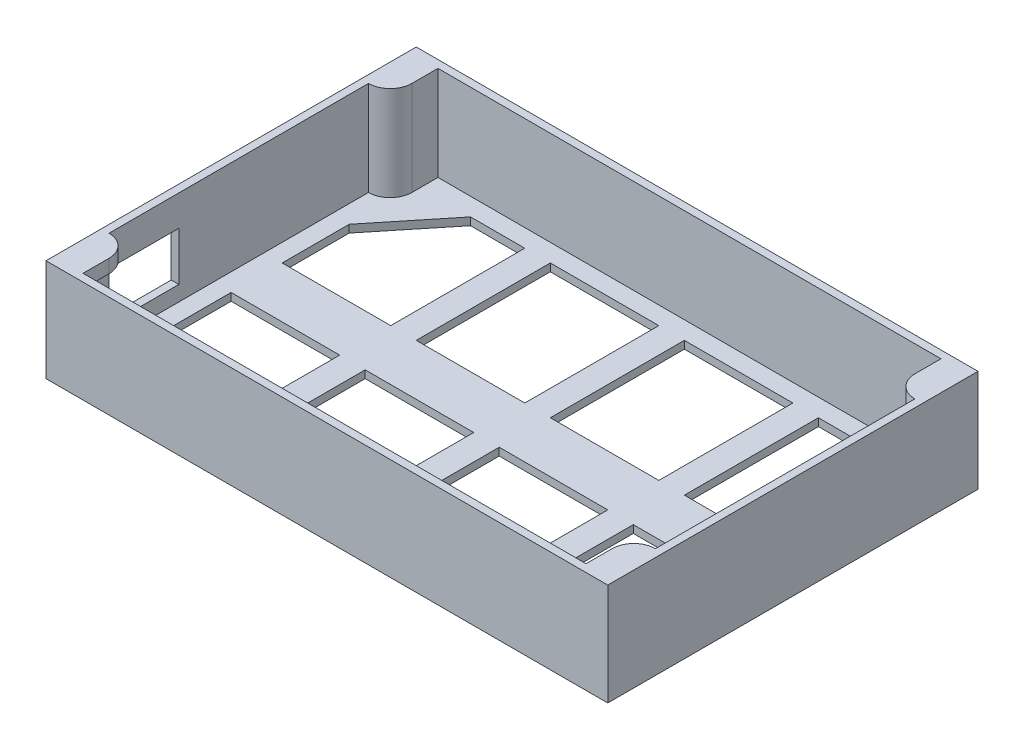
from build123d import *

# Parameters (mm, degrees)
SKETCH1_W           = 220
SKETCH1_H           = 145
SKETCH1_W_2         = 42.5
SKETCH1_H_2         = 52.5
BOSS_EXTRUDE1_DEPTH = 3
SKETCH2_W           = 220
SKETCH2_H           = 145
BOSS_EXTRUDE2_DEPTH = 37
SKETCH3_W           = 27.3375
SKETCH3_H           = 19.05
CUT_EXTRUDE1_DEPTH  = 3
SKETCH3_6_W         = 53.975
SKETCH3_6_H         = 31.75
CUT_EXTRUDE2_DEPTH  = 8.5


with BuildPart() as part:
    # Sketch1 → Boss-Extrude1 (new body)
    with BuildSketch(Plane(origin=(0, 0, 0), x_dir=(1, 0, 0), z_dir=(0, 1, 0))):
        with Locations((110, 72.5)):
            Rectangle(SKETCH1_W, SKETCH1_H)
        Polygon((10, 82.5), (52.5, 82.5), (52.5, 135), (31.25, 135), (10, 108.75), align=None, mode=Mode.SUBTRACT)
        with Locations((83.75, 108.75)):
            Rectangle(SKETCH1_W_2, SKETCH1_H_2, mode=Mode.SUBTRACT)
        with Locations((83.75, 36.25)):
            Rectangle(SKETCH1_W_2, SKETCH1_H_2, mode=Mode.SUBTRACT)
        Polygon((10, 36.25), (31.25, 10), (52.5, 10), (52.5, 62.5), (10, 62.5), align=None, mode=Mode.SUBTRACT)
        Polygon((210, 62.5), (210, 36.25), (188.75, 10), (167.5, 10), (167.5, 62.5), align=None, mode=Mode.SUBTRACT)
        with Locations((136.25, 36.25)):
            Rectangle(SKETCH1_W_2, SKETCH1_H_2, mode=Mode.SUBTRACT)
        with Locations((136.25, 108.75)):
            Rectangle(SKETCH1_W_2, SKETCH1_H_2, mode=Mode.SUBTRACT)
        Polygon((210, 108.75), (188.75, 135), (167.5, 135), (167.5, 82.5), (210, 82.5), align=None, mode=Mode.SUBTRACT)
    extrude(amount=BOSS_EXTRUDE1_DEPTH)

    # Sketch2 → Boss-Extrude2 (add)
    with BuildSketch(Plane(origin=(0, 3, 0), x_dir=(1, 0, 0), z_dir=(0, 1, 0))):
        with Locations((110, 72.5)):
            Rectangle(SKETCH2_W, SKETCH2_H)
        with BuildLine():
            Line((3, 123.3), (3, 21.7))
            ThreePointArc((3, 21.7), (9.01040764, 19.21040764), (11.5, 13.2))
            Line((11.5, 13.2), (11.5, 3))
            Line((11.5, 3), (208.5, 3))
            Line((208.5, 3), (208.5, 13.2))
            ThreePointArc((208.5, 13.2), (210.98959236, 19.21040764), (217, 21.7))
            Line((217, 21.7), (217, 123.3))
            ThreePointArc((217, 123.3), (210.98959236, 125.78959236), (208.5, 131.8))
            Line((208.5, 131.8), (208.5, 142))
            Line((208.5, 142), (11.5, 142))
            Line((11.5, 142), (11.5, 131.8))
            ThreePointArc((11.5, 131.8), (9.01040764, 125.78959236), (3, 123.3))
        make_face(mode=Mode.SUBTRACT)
    extrude(amount=BOSS_EXTRUDE2_DEPTH)

    # Sketch3 → Cut-Extrude1 (cut)
    with BuildSketch(Plane.ZY.offset(-3)):
        with Locations((-35.36875, 18.478125)):
            Rectangle(SKETCH3_W, SKETCH3_H)
    extrude(amount=CUT_EXTRUDE1_DEPTH, mode=Mode.SUBTRACT)

    # Sketch3_6 → Cut-Extrude2 (cut)
    with BuildSketch(Plane.ZY.offset(-3)):
        with Locations((-29.9875, 18.875)):
            Rectangle(SKETCH3_6_W, SKETCH3_6_H)
    extrude(amount=-CUT_EXTRUDE2_DEPTH, mode=Mode.SUBTRACT)


solid = part.part
